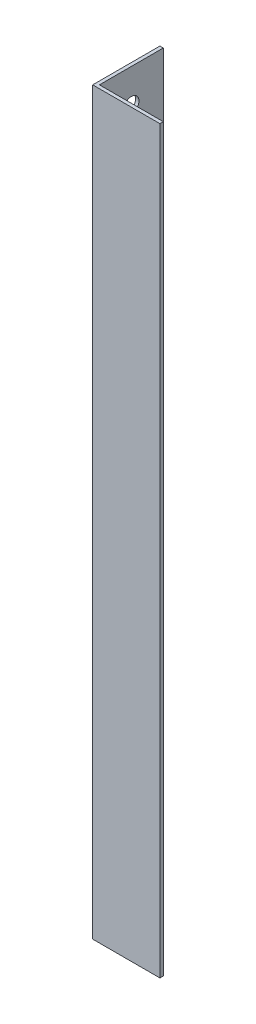
from build123d import *

# Parameters (mm, degrees)
EXTRUDE_1_DEPTH     = 220
SKETCH_2_R          = 4.25
CUT_EXTRUDE_1_DEPTH = 2
SKETCH_3_R          = 2.25
CUT_EXTRUDE_2_DEPTH = 2
SKETCH_4_R          = 2.25
CUT_EXTRUDE_3_DEPTH = 2


with BuildPart() as part:
    # Эскиз1 → Бобышка-Вытянуть1 (new body)
    with BuildSketch(Plane(origin=(0, 0, 0), x_dir=(1, 0, 0), z_dir=(0, 1, 0))):
        Polygon((0, 0), (0, 20), (1, 20), (1, 1), (20, 1), (20, 0), align=None)
    extrude(amount=EXTRUDE_1_DEPTH)

    # Эскиз2 → Вырез-Вытянуть1 (cut, through all)
    with BuildSketch(Plane(origin=(1, 0, 0), x_dir=(0, 0, -1), z_dir=(1, 0, 0))):
        with Locations((10.5, 180)):
            Circle(SKETCH_2_R)
        with Locations((10.5, 120)):
            Circle(SKETCH_2_R)
        with Locations((10.5, 60)):
            Circle(SKETCH_2_R)
    extrude(amount=-CUT_EXTRUDE_1_DEPTH, mode=Mode.SUBTRACT)

    # Эскиз3 → Вырез-Вытянуть2 (cut, through all)
    with BuildSketch(Plane(origin=(1, 0, 0), x_dir=(0, 0, -1), z_dir=(1, 0, 0))):
        with Locations((10.5, 210)):
            Circle(SKETCH_3_R)
    extrude(amount=-CUT_EXTRUDE_2_DEPTH, mode=Mode.SUBTRACT)

    # Эскиз4 → Вырез-Вытянуть3 (cut, through all)
    with BuildSketch(Plane(origin=(1, 0, 0), x_dir=(0, 0, -1), z_dir=(1, 0, 0))):
        with Locations((10.5, 10)):
            Circle(SKETCH_4_R)
    extrude(amount=-CUT_EXTRUDE_3_DEPTH, mode=Mode.SUBTRACT)


solid = part.part
